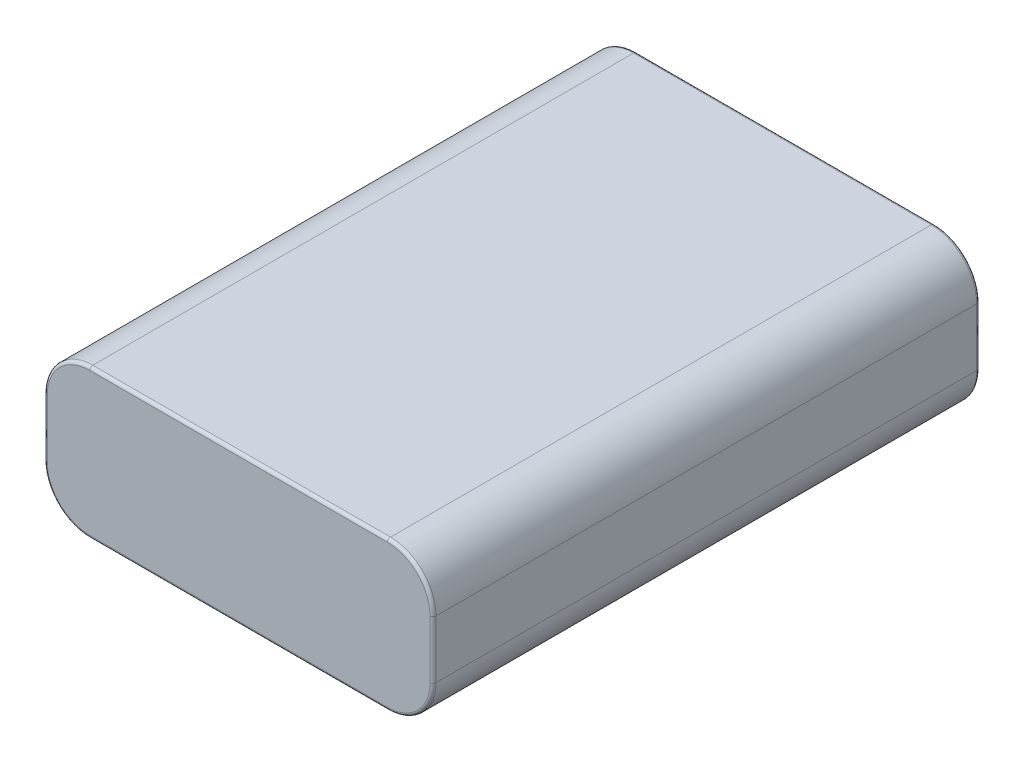
from build123d import *

# Parameters (mm, degrees)
CROQUIS1_W              = 64
CROQUIS1_H              = 90
SALIENTE_EXTRUIR1_DEPTH = 24.5
REDONDEO1_R             = 7.5
REDONDEO2_R             = 0.5


with BuildPart() as part:
    # Croquis1 → Saliente-Extruir1 (new body)
    with BuildSketch(Plane(origin=(0, 0, 0), x_dir=(1, 0, 0), z_dir=(0, 1, 0))):
        Rectangle(CROQUIS1_W, CROQUIS1_H)
    extrude(amount=SALIENTE_EXTRUIR1_DEPTH)

    # Redondeo1
    redondeo1_edges = [part.edges().sort_by_distance(p)[0] for p in [
        (-32, 24.5, 0),
        (32, 24.5, 0),
        (-32, 0, 0),
        (32, 0, 0),
    ]]
    fillet(redondeo1_edges, radius=REDONDEO1_R)

    # Redondeo2
    redondeo2_edges = [part.edges().sort_by_distance(p)[0] for p in [
        (-32, 12.25, 45),
        (-32, 12.25, -45),
        (0, 0, 45),
        (32, 12.25, 45),
        (0, 24.5, 45),
        (29.803300859, 22.303300859, 45),
        (29.803300859, 2.196699141, 45),
        (-29.803300859, 22.303300859, 45),
        (-29.803300859, 2.196699141, 45),
        (0, 0, -45),
        (0, 24.5, -45),
        (32, 12.25, -45),
        (29.803300859, 22.303300859, -45),
        (29.803300859, 2.196699141, -45),
        (-29.803300859, 22.303300859, -45),
        (-29.803300859, 2.196699141, -45),
    ]]
    fillet(redondeo2_edges, radius=REDONDEO2_R)


solid = part.part
